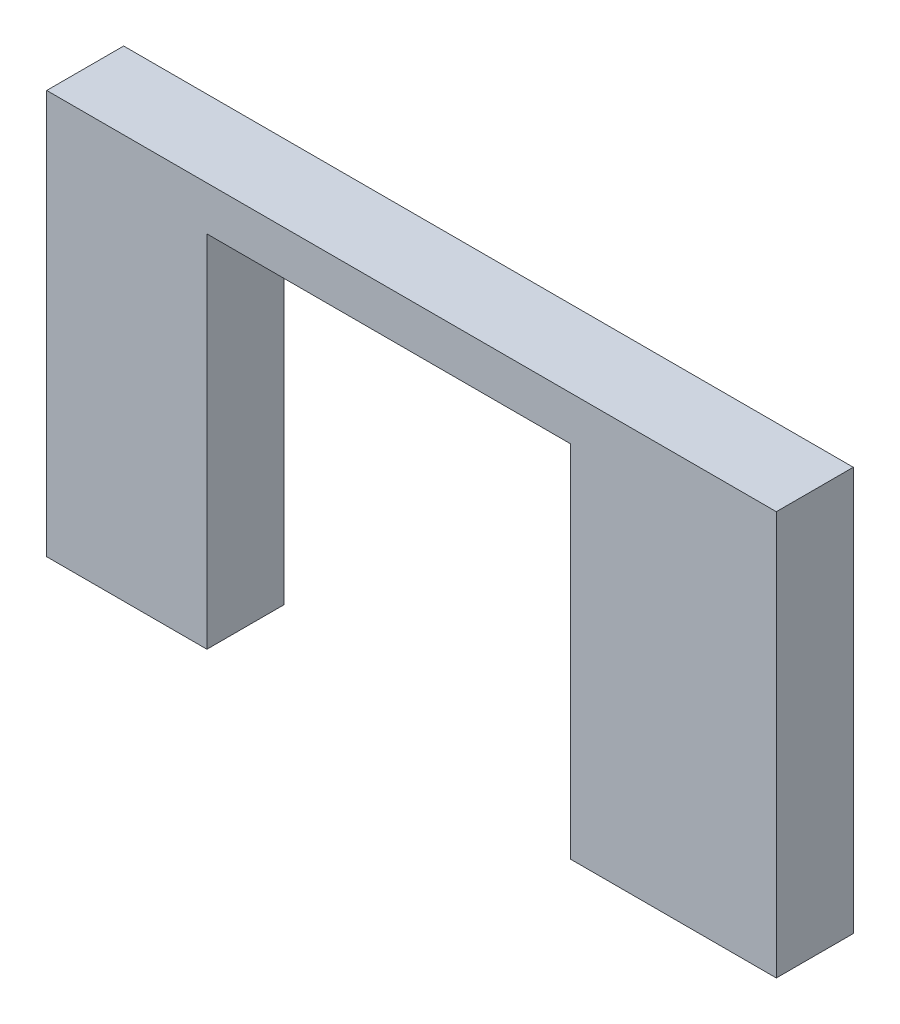
from build123d import *

# Parameters (mm, degrees)
SKETCH1_W           = 30.1
SKETCH1_H           = 16.66
BOSS_EXTRUDE1_DEPTH = 3.175
SKETCH2_W           = 15
SKETCH2_H           = 15
CUT_EXTRUDE1_DEPTH  = 4.175


with BuildPart() as part:
    # Sketch1 → Boss-Extrude1 (new body)
    with BuildSketch(Plane.XY):
        with Locations((15.05, 8.33)):
            Rectangle(SKETCH1_W, SKETCH1_H)
    extrude(amount=BOSS_EXTRUDE1_DEPTH)

    # Sketch2 → Cut-Extrude1 (cut, through all)
    with BuildSketch(Plane.XY.offset(3.175)):
        with Locations((14.11, 7.34)):
            Rectangle(SKETCH2_W, SKETCH2_H)
    extrude(amount=-CUT_EXTRUDE1_DEPTH, mode=Mode.SUBTRACT)


solid = part.part
